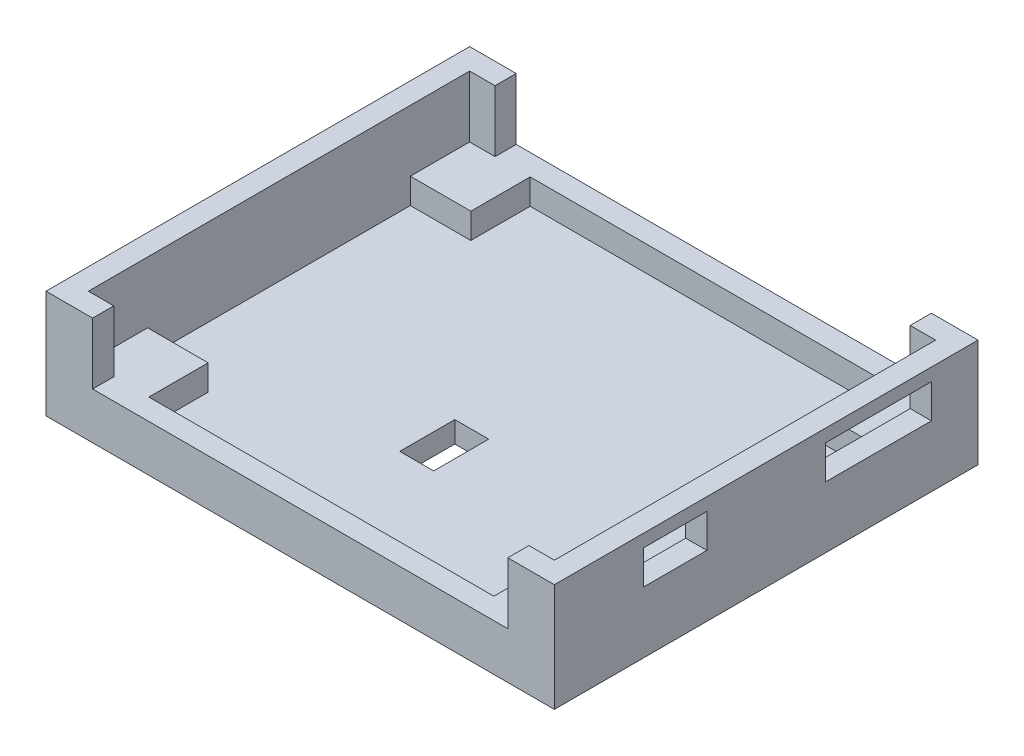
from build123d import *

# Parameters (mm, degrees)
CROQUIS1_W              = 60
CROQUIS1_H              = 50
SALIENTE_EXTRUIR1_DEPTH = 12.75
CORTAR_EXTRUIR2_START   = 12.75
CROQUIS2_W              = 55
CROQUIS2_H              = 45
CORTAR_EXTRUIR2_DEPTH   = 10.25
CROQUIS3_W              = 4
CROQUIS3_H              = 6.5
CORTAR_EXTRUIR3_DEPTH   = 10.25
CROQUIS5_W              = 49
CROQUIS5_H              = 7.25
CORTAR_EXTRUIR4_DEPTH   = 45.125
CROQUIS6_W              = 7.5
CROQUIS6_H              = 4
CROQUIS6_W_2            = 12.5
CORTAR_EXTRUIR5_DEPTH   = 60
CROQUIS8_W              = 7.141428429
CROQUIS8_H              = 7
SALIENTE_EXTRUIR6_DEPTH = 5.5


with BuildPart() as part:
    # Croquis1 → Saliente-Extruir1 (new body)
    with BuildSketch(Plane(origin=(0, 0, 0), x_dir=(1, 0, 0), z_dir=(0, 1, 0))):
        Rectangle(CROQUIS1_W, CROQUIS1_H)
    extrude(amount=SALIENTE_EXTRUIR1_DEPTH)

    # Croquis2 → Cortar-Extruir2 (cut)
    with BuildSketch(Plane(origin=(0, 0, 0), x_dir=(1, 0, 0), z_dir=(0, 1, 0)).offset(CORTAR_EXTRUIR2_START)):
        Rectangle(CROQUIS2_W, CROQUIS2_H)
    extrude(amount=-CORTAR_EXTRUIR2_DEPTH, mode=Mode.SUBTRACT)

    # Croquis3 → Cortar-Extruir3 (cut)
    with BuildSketch(Plane(origin=(0, 0, 0), x_dir=(1, 0, 0), z_dir=(0, 1, 0))):
        with Locations((-1, -7)):
            Rectangle(CROQUIS3_W, CROQUIS3_H)
    extrude(amount=CORTAR_EXTRUIR3_DEPTH, mode=Mode.SUBTRACT)

    # Croquis5 → Cortar-Extruir4 (cut, symmetric)
    with BuildSketch(Plane.XY):
        with Locations((0, 9.125)):
            Rectangle(CROQUIS5_W, CROQUIS5_H)
    extrude(amount=CORTAR_EXTRUIR4_DEPTH, both=True, mode=Mode.SUBTRACT)

    # Croquis6 → Cortar-Extruir5 (cut)
    with BuildSketch(Plane(origin=(0, 0, 0), x_dir=(0, 0, -1), z_dir=(1, 0, 0))):
        with Locations((-10.75, 9.25)):
            Rectangle(CROQUIS6_W, CROQUIS6_H)
        with Locations((13.25, 9.25)):
            Rectangle(CROQUIS6_W_2, CROQUIS6_H)
    extrude(amount=CORTAR_EXTRUIR5_DEPTH, mode=Mode.SUBTRACT)

    # Croquis8 → Saliente-Extruir6 (add)
    with BuildSketch(Plane(origin=(0, 0, 0), x_dir=(1, 0, 0), z_dir=(0, 1, 0))):
        with Locations((23.929285785, -19)):
            Rectangle(CROQUIS8_W, CROQUIS8_H)
        with Locations((-23.929285785, -19)):
            Rectangle(CROQUIS8_W, CROQUIS8_H)
        with Locations((23.929285785, 19)):
            Rectangle(CROQUIS8_W, CROQUIS8_H)
        with Locations((-23.929285785, 19)):
            Rectangle(CROQUIS8_W, CROQUIS8_H)
    extrude(amount=SALIENTE_EXTRUIR6_DEPTH)


solid = part.part
